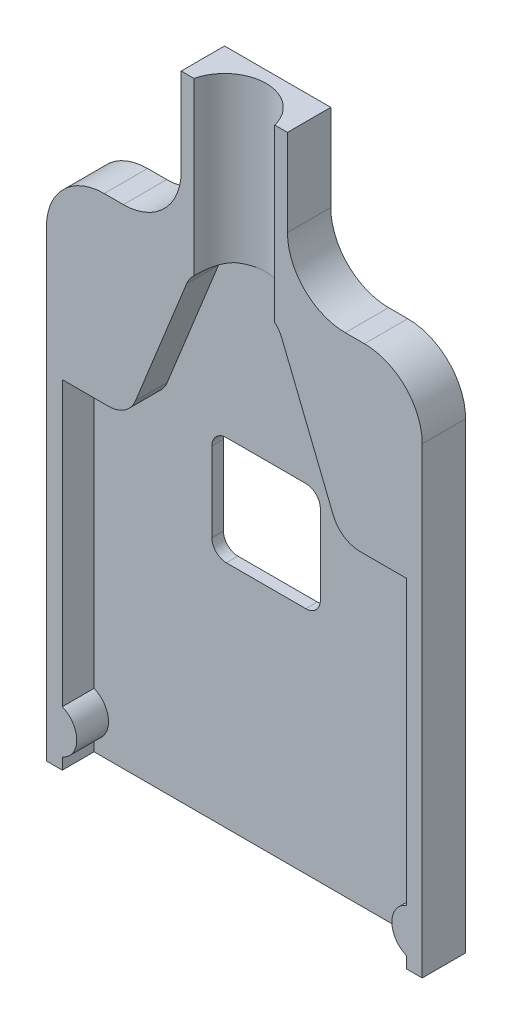
from build123d import *

# Parameters (mm, degrees)
BOSS_EXTRUDE1_DEPTH = 3
CUT_EXTRUDE1_DEPTH  = 2.2
SKETCH3_R           = 2.875
CUT_EXTRUDE2_DEPTH  = 22.6
CUT_EXTRUDE3_DEPTH  = 2.2
FILLET1_R           = 2
FILLET2_R           = 4
FILLET3_R           = 4
SKETCH5_W           = 7.5
SKETCH5_H           = 7.5
CUT_EXTRUDE4_DEPTH  = 0.8
FILLET4_R           = 1


with BuildPart() as part:
    # Sketch1 → Boss-Extrude1 (new body)
    with BuildSketch(Plane.XY):
        Polygon((0, 36), (9.325, 36), (9.325, 46), (16.675, 46), (16.675, 36), (26, 36), (26, 0), (0, 0), align=None)
    extrude(amount=BOSS_EXTRUDE1_DEPTH)

    # Sketch2 → Cut-Extrude1 (cut)
    with BuildSketch(Plane.XY.offset(3)):
        with BuildLine():
            Line((1.1, -0.4), (1.1, 0.795839104))
            ThreePointArc((1.1, 0.795839104), (2.1, 2.3), (1.1, 3.804160896))
            Line((1.1, 3.804160896), (1.1, 23.4))
            Line((1.1, 23.4), (24.9, 23.4))
            Line((24.9, 23.4), (24.9, 3.804160896))
            ThreePointArc((24.9, 3.804160896), (23.9, 2.3), (24.9, 0.795839104))
            Line((24.9, 0.795839104), (24.9, -0.4))
            Line((24.9, -0.4), (1.1, -0.4))
        make_face()
    extrude(amount=-CUT_EXTRUDE1_DEPTH, mode=Mode.SUBTRACT)

    # Sketch3 → Cut-Extrude2 (cut)
    with BuildSketch(Plane(origin=(0, 46, 0), x_dir=(1, 0, 0), z_dir=(0, 1, 0))):
        with Locations((13, -3.675)):
            Circle(SKETCH3_R)
    extrude(amount=-CUT_EXTRUDE2_DEPTH, mode=Mode.SUBTRACT)

    # Sketch4 → Cut-Extrude3 (cut)
    with BuildSketch(Plane.XY.offset(3)):
        Polygon((5.652681139, 23.4), (10.205362278, 34.7), (15.794637722, 34.7), (20.347318861, 23.4), align=None)
    extrude(amount=-CUT_EXTRUDE3_DEPTH, mode=Mode.SUBTRACT)

    # Fillet1
    fillet1_edges = [part.edges().sort_by_distance(p)[0] for p in [
        (10.205362278, 34.7, 1.9),
        (20.347318861, 23.4, 1.9),
        (15.794637722, 34.7, 1.9),
        (5.652681139, 23.4, 1.9),
    ]]
    fillet(fillet1_edges, radius=FILLET1_R)

    # Fillet2
    fillet2_edges = [part.edges().sort_by_distance(p)[0] for p in [
        (0, 36, 1.5),
        (26, 36, 1.5),
    ]]
    fillet(fillet2_edges, radius=FILLET2_R)

    # Fillet3
    fillet3_edges = [part.edges().sort_by_distance(p)[0] for p in [
        (9.325, 36, 1.5),
        (16.675, 36, 1.5),
    ]]
    fillet(fillet3_edges, radius=FILLET3_R)

    # Sketch5 → Cut-Extrude4 (cut)
    with BuildSketch(Plane.XY.offset(0.8)):
        with Locations((13, 19.65)):
            Rectangle(SKETCH5_W, SKETCH5_H)
    extrude(amount=-CUT_EXTRUDE4_DEPTH, mode=Mode.SUBTRACT)

    # Fillet4
    fillet4_edges = [part.edges().sort_by_distance(p)[0] for p in [
        (16.75, 15.9, 0.4),
        (16.75, 23.4, 0.4),
        (9.25, 23.4, 0.4),
        (9.25, 15.9, 0.4),
    ]]
    fillet(fillet4_edges, radius=FILLET4_R)


solid = part.part
